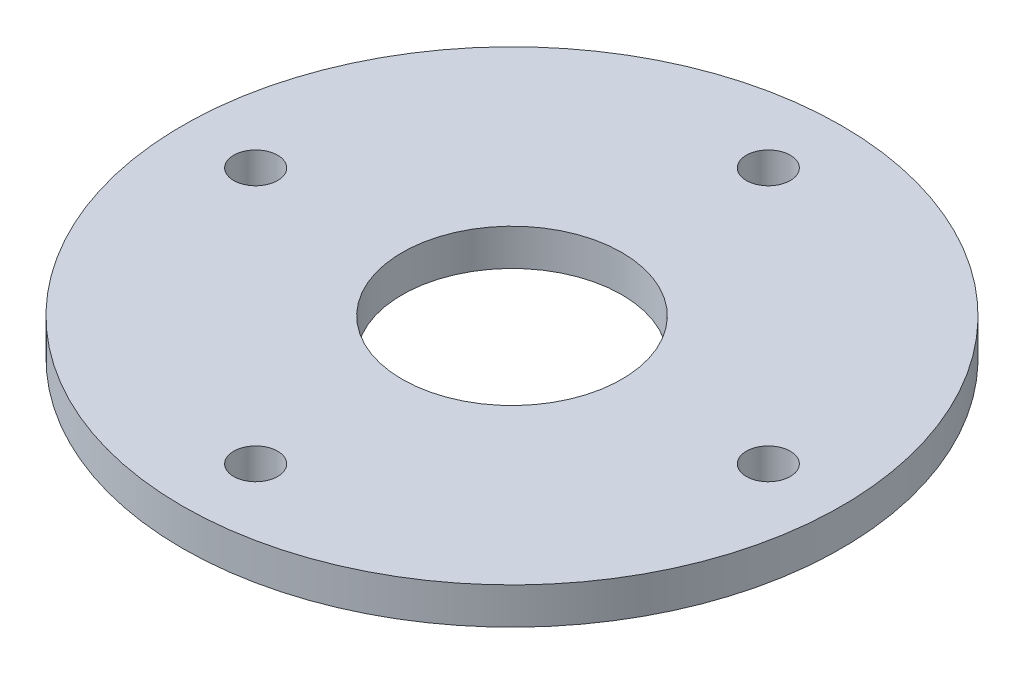
from build123d import *

# Parameters (mm, degrees)
SKETCH_1_R      = 45
SKETCH_1_R_2    = 3
SKETCH_1_R_3    = 15
EXTRUDE_3_DEPTH = 5


with BuildPart() as part:
    # 草圖1 → 填料-伸長3 (new body)
    with BuildSketch(Plane(origin=(0, 0, 0), x_dir=(1, 0, 0), z_dir=(0, 1, 0))):
        Circle(SKETCH_1_R)
        with Locations((-35, 0)):
            Circle(SKETCH_1_R_2, mode=Mode.SUBTRACT)
        with Locations((35, 0)):
            Circle(SKETCH_1_R_2, mode=Mode.SUBTRACT)
        with Locations((0, -35)):
            Circle(SKETCH_1_R_2, mode=Mode.SUBTRACT)
        with Locations((0, 35)):
            Circle(SKETCH_1_R_2, mode=Mode.SUBTRACT)
        Circle(SKETCH_1_R_3, mode=Mode.SUBTRACT)
    extrude(amount=EXTRUDE_3_DEPTH)


solid = part.part
